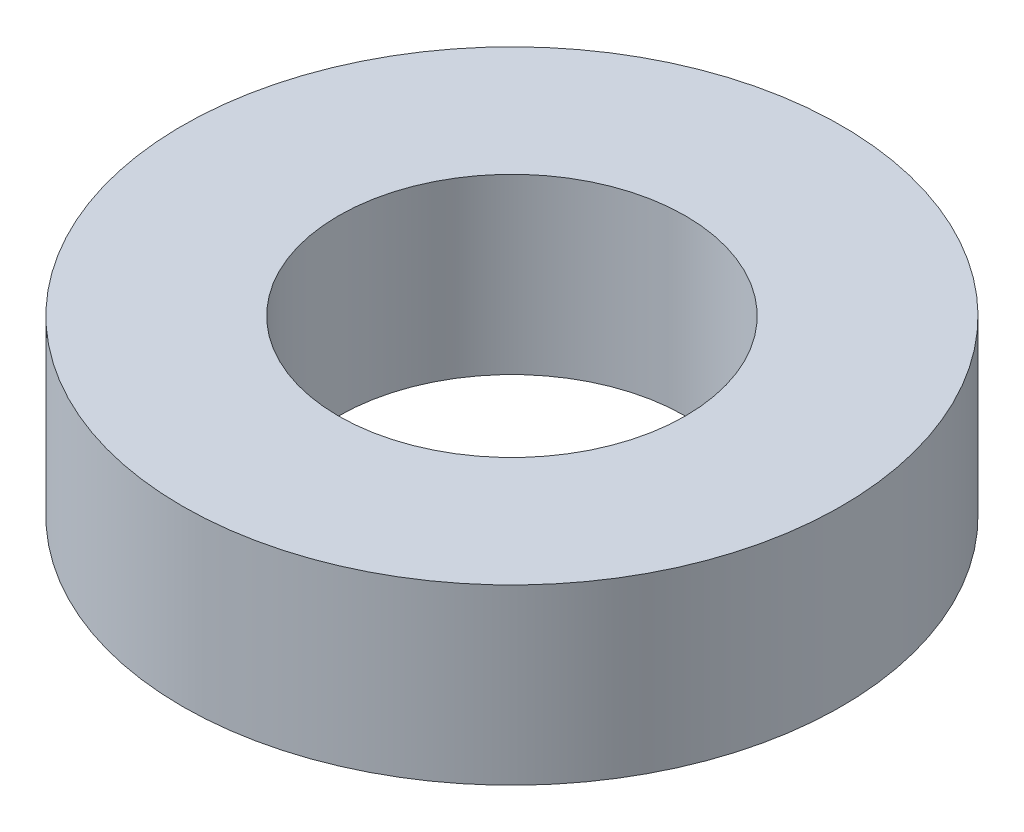
from build123d import *

# Parameters (mm, degrees)
SKETCH_1_R      = 9.5
SKETCH_1_R_2    = 5
EXTRUDE_1_DEPTH = 5


with BuildPart() as part:
    # 草图1 → 凸台-拉伸1 (new body)
    with BuildSketch(Plane(origin=(0, 0, 0), x_dir=(1, 0, 0), z_dir=(0, 1, 0))):
        Circle(SKETCH_1_R)
        Circle(SKETCH_1_R_2, mode=Mode.SUBTRACT)
    extrude(amount=EXTRUDE_1_DEPTH)


solid = part.part
